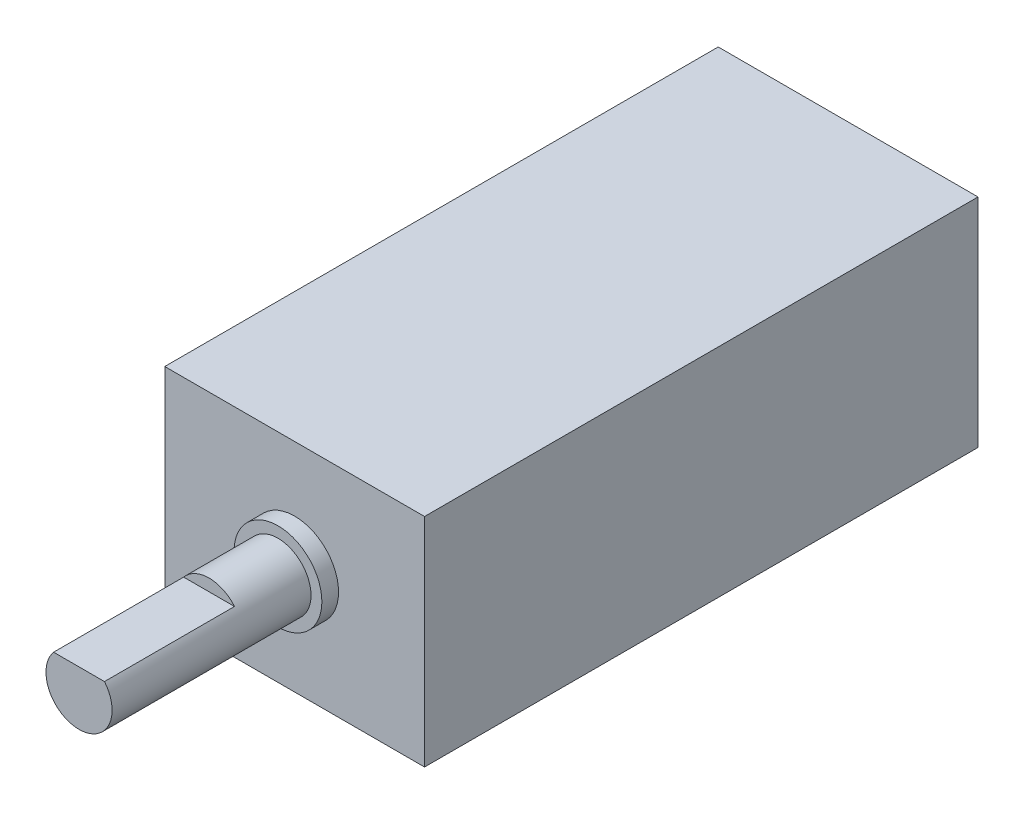
from build123d import *

# Parameters (mm, degrees)
SKETCH1_W           = 11.8745
SKETCH1_H           = 9.9187
BOSS_EXTRUDE1_DEPTH = 25.2984
SKETCH2_R           = 2.0066
BOSS_EXTRUDE2_DEPTH = 0.762
SKETCH3_R           = 1.5113
BOSS_EXTRUDE3_DEPTH = 9.0932
CUT_EXTRUDE1_DEPTH  = 5.9436


with BuildPart() as part:
    # Sketch1 → Boss-Extrude1 (new body)
    with BuildSketch(Plane.XY):
        Rectangle(SKETCH1_W, SKETCH1_H)
    extrude(amount=-BOSS_EXTRUDE1_DEPTH)

    # Sketch2 → Boss-Extrude2 (add)
    with BuildSketch(Plane.XY):
        Circle(SKETCH2_R)
    extrude(amount=BOSS_EXTRUDE2_DEPTH)

    # Sketch3 → Boss-Extrude3 (add)
    with BuildSketch(Plane.XY.offset(0.762)):
        Circle(SKETCH3_R)
    extrude(amount=BOSS_EXTRUDE3_DEPTH)

    # Sketch4 → Cut-Extrude1 (cut)
    with BuildSketch(Plane.XY.offset(9.8552)):
        Polygon((-31.544055033, 0.9652), (-1.667569456, 0.9652), (2.041996645, 0.9652), (31.918482222, 0.9652), (31.918482222, 60.718171154), (-31.544055033, 60.718171154), align=None)
    extrude(amount=-CUT_EXTRUDE1_DEPTH, mode=Mode.SUBTRACT)


solid = part.part
